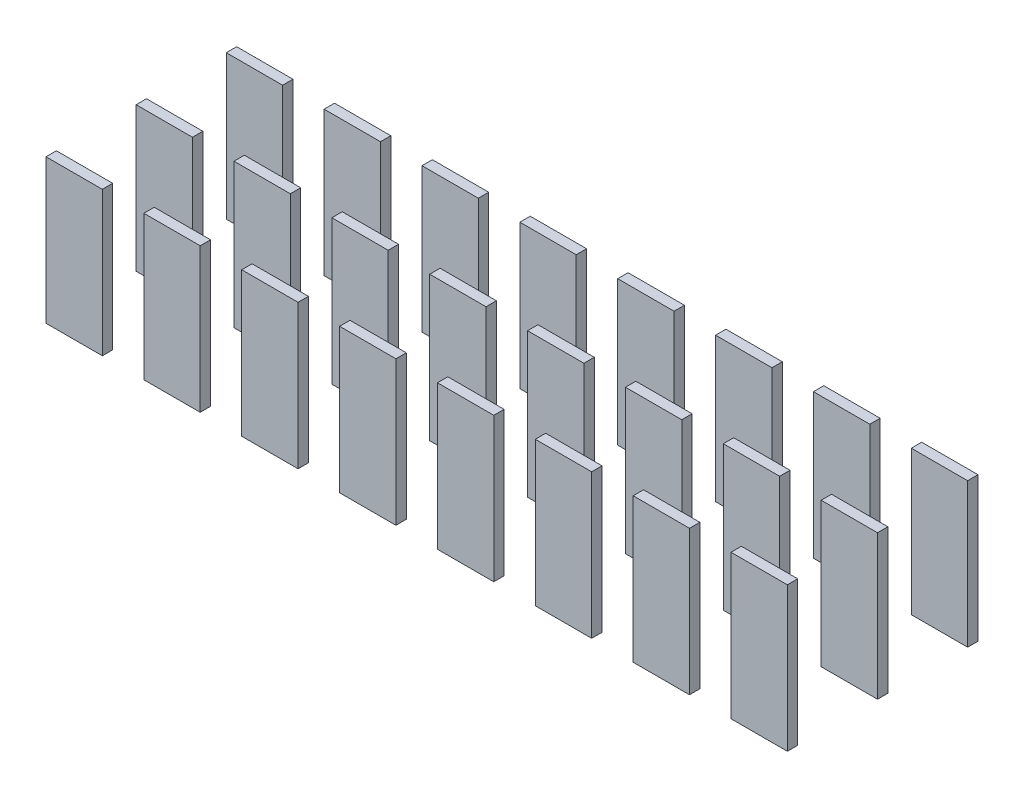
from build123d import *

# Parameters (mm, degrees)
SKETCH1_W              = 3.175
SKETCH1_H              = 0.5842
BOSS_EXTRUDE1_DEPTH    = 8.128
BOSS_EXTRUDE1_2_DEPTH  = 8.128
BOSS_EXTRUDE1_3_DEPTH  = 8.128
BOSS_EXTRUDE1_4_DEPTH  = 8.128
BOSS_EXTRUDE1_5_DEPTH  = 8.128
BOSS_EXTRUDE1_6_DEPTH  = 8.128
BOSS_EXTRUDE1_7_DEPTH  = 8.128
BOSS_EXTRUDE1_8_DEPTH  = 8.128
BOSS_EXTRUDE1_9_DEPTH  = 8.128
BOSS_EXTRUDE1_10_DEPTH = 8.128
BOSS_EXTRUDE1_11_DEPTH = 8.128
BOSS_EXTRUDE1_12_DEPTH = 8.128
BOSS_EXTRUDE1_13_DEPTH = 8.128
BOSS_EXTRUDE1_14_DEPTH = 8.128
BOSS_EXTRUDE1_15_DEPTH = 8.128
BOSS_EXTRUDE1_16_DEPTH = 8.128
BOSS_EXTRUDE1_17_DEPTH = 8.128
BOSS_EXTRUDE1_18_DEPTH = 8.128
BOSS_EXTRUDE1_19_DEPTH = 8.128
BOSS_EXTRUDE1_20_DEPTH = 8.128
BOSS_EXTRUDE1_21_DEPTH = 8.128
BOSS_EXTRUDE1_22_DEPTH = 8.128
BOSS_EXTRUDE1_23_DEPTH = 8.128
BOSS_EXTRUDE1_24_DEPTH = 8.128


with BuildPart() as part:
    # Sketch1 → Boss-Extrude1 (new body)
    with BuildSketch(Plane(origin=(0, 0, 0), x_dir=(1, 0, 0), z_dir=(0, 1, 0))):
        with Locations((7.102928571, 0.2921)):
            Rectangle(SKETCH1_W, SKETCH1_H)
    extrude(amount=BOSS_EXTRUDE1_DEPTH)


with BuildPart() as body_2:
    # Sketch1 → Boss-Extrude1 2 (new body)
    with BuildSketch(Plane(origin=(0, 0, 0), x_dir=(1, 0, 0), z_dir=(0, 1, 0))):
        with Locations((1.5875, 0.2921)):
            Rectangle(SKETCH1_W, SKETCH1_H)
    extrude(amount=BOSS_EXTRUDE1_2_DEPTH)


with BuildPart() as body_3:
    # Sketch1 → Boss-Extrude1 3 (new body)
    with BuildSketch(Plane(origin=(0, 0, 0), x_dir=(1, 0, 0), z_dir=(0, 1, 0))):
        with Locations((12.618357143, 0.2921)):
            Rectangle(SKETCH1_W, SKETCH1_H)
    extrude(amount=BOSS_EXTRUDE1_3_DEPTH)


with BuildPart() as body_4:
    # Sketch1 → Boss-Extrude1 4 (new body)
    with BuildSketch(Plane(origin=(0, 0, 0), x_dir=(1, 0, 0), z_dir=(0, 1, 0))):
        with Locations((18.133785714, 0.2921)):
            Rectangle(SKETCH1_W, SKETCH1_H)
    extrude(amount=BOSS_EXTRUDE1_4_DEPTH)


with BuildPart() as body_5:
    # Sketch1 → Boss-Extrude1 5 (new body)
    with BuildSketch(Plane(origin=(0, 0, 0), x_dir=(1, 0, 0), z_dir=(0, 1, 0))):
        with Locations((23.649214286, 0.2921)):
            Rectangle(SKETCH1_W, SKETCH1_H)
    extrude(amount=BOSS_EXTRUDE1_5_DEPTH)


with BuildPart() as body_6:
    # Sketch1 → Boss-Extrude1 6 (new body)
    with BuildSketch(Plane(origin=(0, 0, 0), x_dir=(1, 0, 0), z_dir=(0, 1, 0))):
        with Locations((29.164642857, 0.2921)):
            Rectangle(SKETCH1_W, SKETCH1_H)
    extrude(amount=BOSS_EXTRUDE1_6_DEPTH)


with BuildPart() as body_7:
    # Sketch1 → Boss-Extrude1 7 (new body)
    with BuildSketch(Plane(origin=(0, 0, 0), x_dir=(1, 0, 0), z_dir=(0, 1, 0))):
        with Locations((34.680071429, 0.2921)):
            Rectangle(SKETCH1_W, SKETCH1_H)
    extrude(amount=BOSS_EXTRUDE1_7_DEPTH)


with BuildPart() as body_8:
    # Sketch1 → Boss-Extrude1 8 (new body)
    with BuildSketch(Plane(origin=(0, 0, 0), x_dir=(1, 0, 0), z_dir=(0, 1, 0))):
        with Locations((40.1955, 0.2921)):
            Rectangle(SKETCH1_W, SKETCH1_H)
    extrude(amount=BOSS_EXTRUDE1_8_DEPTH)


with BuildPart() as body_9:
    # Sketch1 → Boss-Extrude1 9 (new body)
    with BuildSketch(Plane(origin=(0, 0, 0), x_dir=(1, 0, 0), z_dir=(0, 1, 0))):
        with Locations((7.102928571, 5.3721)):
            Rectangle(SKETCH1_W, SKETCH1_H)
    extrude(amount=BOSS_EXTRUDE1_9_DEPTH)


with BuildPart() as body_10:
    # Sketch1 → Boss-Extrude1 10 (new body)
    with BuildSketch(Plane(origin=(0, 0, 0), x_dir=(1, 0, 0), z_dir=(0, 1, 0))):
        with Locations((1.5875, 5.3721)):
            Rectangle(SKETCH1_W, SKETCH1_H)
    extrude(amount=BOSS_EXTRUDE1_10_DEPTH)


with BuildPart() as body_11:
    # Sketch1 → Boss-Extrude1 11 (new body)
    with BuildSketch(Plane(origin=(0, 0, 0), x_dir=(1, 0, 0), z_dir=(0, 1, 0))):
        with Locations((12.618357143, 5.3721)):
            Rectangle(SKETCH1_W, SKETCH1_H)
    extrude(amount=BOSS_EXTRUDE1_11_DEPTH)


with BuildPart() as body_12:
    # Sketch1 → Boss-Extrude1 12 (new body)
    with BuildSketch(Plane(origin=(0, 0, 0), x_dir=(1, 0, 0), z_dir=(0, 1, 0))):
        with Locations((18.133785714, 5.3721)):
            Rectangle(SKETCH1_W, SKETCH1_H)
    extrude(amount=BOSS_EXTRUDE1_12_DEPTH)


with BuildPart() as body_13:
    # Sketch1 → Boss-Extrude1 13 (new body)
    with BuildSketch(Plane(origin=(0, 0, 0), x_dir=(1, 0, 0), z_dir=(0, 1, 0))):
        with Locations((23.649214286, 5.3721)):
            Rectangle(SKETCH1_W, SKETCH1_H)
    extrude(amount=BOSS_EXTRUDE1_13_DEPTH)


with BuildPart() as body_14:
    # Sketch1 → Boss-Extrude1 14 (new body)
    with BuildSketch(Plane(origin=(0, 0, 0), x_dir=(1, 0, 0), z_dir=(0, 1, 0))):
        with Locations((29.164642857, 5.3721)):
            Rectangle(SKETCH1_W, SKETCH1_H)
    extrude(amount=BOSS_EXTRUDE1_14_DEPTH)


with BuildPart() as body_15:
    # Sketch1 → Boss-Extrude1 15 (new body)
    with BuildSketch(Plane(origin=(0, 0, 0), x_dir=(1, 0, 0), z_dir=(0, 1, 0))):
        with Locations((34.680071429, 5.3721)):
            Rectangle(SKETCH1_W, SKETCH1_H)
    extrude(amount=BOSS_EXTRUDE1_15_DEPTH)


with BuildPart() as body_16:
    # Sketch1 → Boss-Extrude1 16 (new body)
    with BuildSketch(Plane(origin=(0, 0, 0), x_dir=(1, 0, 0), z_dir=(0, 1, 0))):
        with Locations((40.1955, 5.3721)):
            Rectangle(SKETCH1_W, SKETCH1_H)
    extrude(amount=BOSS_EXTRUDE1_16_DEPTH)


with BuildPart() as body_17:
    # Sketch1 → Boss-Extrude1 17 (new body)
    with BuildSketch(Plane(origin=(0, 0, 0), x_dir=(1, 0, 0), z_dir=(0, 1, 0))):
        with Locations((7.102928571, 10.4521)):
            Rectangle(SKETCH1_W, SKETCH1_H)
    extrude(amount=BOSS_EXTRUDE1_17_DEPTH)


with BuildPart() as body_18:
    # Sketch1 → Boss-Extrude1 18 (new body)
    with BuildSketch(Plane(origin=(0, 0, 0), x_dir=(1, 0, 0), z_dir=(0, 1, 0))):
        with Locations((1.5875, 10.4521)):
            Rectangle(SKETCH1_W, SKETCH1_H)
    extrude(amount=BOSS_EXTRUDE1_18_DEPTH)


with BuildPart() as body_19:
    # Sketch1 → Boss-Extrude1 19 (new body)
    with BuildSketch(Plane(origin=(0, 0, 0), x_dir=(1, 0, 0), z_dir=(0, 1, 0))):
        with Locations((12.618357143, 10.4521)):
            Rectangle(SKETCH1_W, SKETCH1_H)
    extrude(amount=BOSS_EXTRUDE1_19_DEPTH)


with BuildPart() as body_20:
    # Sketch1 → Boss-Extrude1 20 (new body)
    with BuildSketch(Plane(origin=(0, 0, 0), x_dir=(1, 0, 0), z_dir=(0, 1, 0))):
        with Locations((18.133785714, 10.4521)):
            Rectangle(SKETCH1_W, SKETCH1_H)
    extrude(amount=BOSS_EXTRUDE1_20_DEPTH)


with BuildPart() as body_21:
    # Sketch1 → Boss-Extrude1 21 (new body)
    with BuildSketch(Plane(origin=(0, 0, 0), x_dir=(1, 0, 0), z_dir=(0, 1, 0))):
        with Locations((23.649214286, 10.4521)):
            Rectangle(SKETCH1_W, SKETCH1_H)
    extrude(amount=BOSS_EXTRUDE1_21_DEPTH)


with BuildPart() as body_22:
    # Sketch1 → Boss-Extrude1 22 (new body)
    with BuildSketch(Plane(origin=(0, 0, 0), x_dir=(1, 0, 0), z_dir=(0, 1, 0))):
        with Locations((29.164642857, 10.4521)):
            Rectangle(SKETCH1_W, SKETCH1_H)
    extrude(amount=BOSS_EXTRUDE1_22_DEPTH)


with BuildPart() as body_23:
    # Sketch1 → Boss-Extrude1 23 (new body)
    with BuildSketch(Plane(origin=(0, 0, 0), x_dir=(1, 0, 0), z_dir=(0, 1, 0))):
        with Locations((34.680071429, 10.4521)):
            Rectangle(SKETCH1_W, SKETCH1_H)
    extrude(amount=BOSS_EXTRUDE1_23_DEPTH)


with BuildPart() as body_24:
    # Sketch1 → Boss-Extrude1 24 (new body)
    with BuildSketch(Plane(origin=(0, 0, 0), x_dir=(1, 0, 0), z_dir=(0, 1, 0))):
        with Locations((40.1955, 10.4521)):
            Rectangle(SKETCH1_W, SKETCH1_H)
    extrude(amount=BOSS_EXTRUDE1_24_DEPTH)


solid = Compound([part.part, body_2.part, body_3.part, body_4.part, body_5.part, body_6.part, body_7.part, body_8.part, body_9.part, body_10.part, body_11.part, body_12.part, body_13.part, body_14.part, body_15.part, body_16.part, body_17.part, body_18.part, body_19.part, body_20.part, body_21.part, body_22.part, body_23.part, body_24.part])
